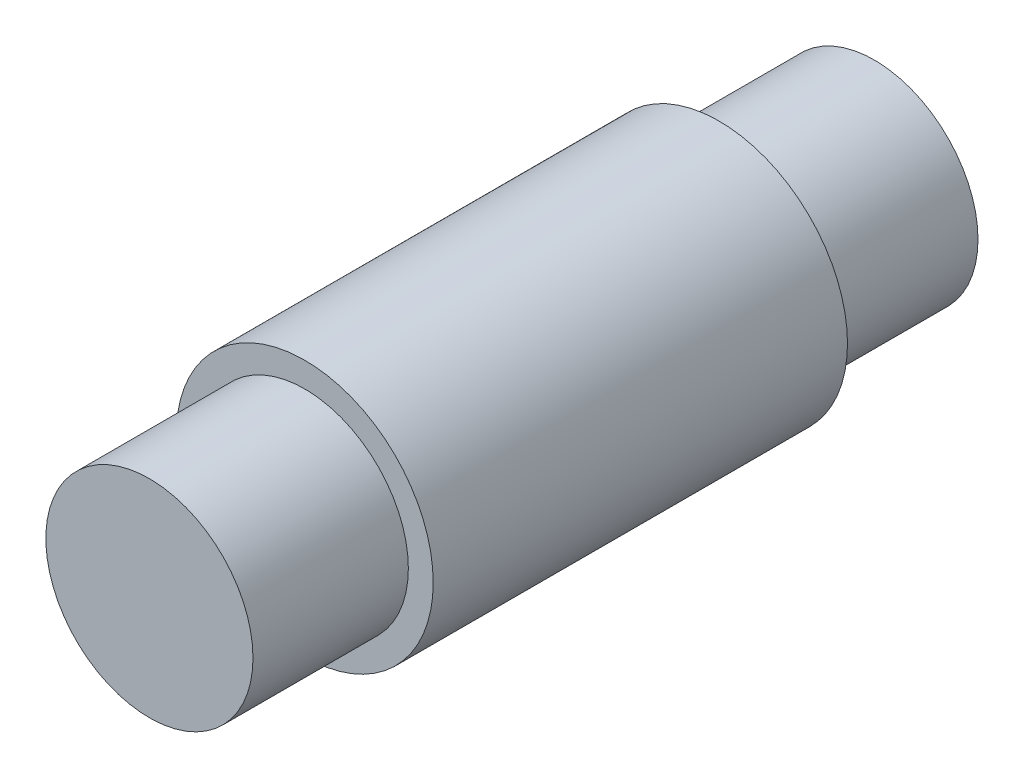
from build123d import *

# Parameters (mm, degrees)
SKETCH3_R           = 1.55
BOSS_EXTRUDE1_DEPTH = 2.5
SKETCH4_R           = 1.25
BOSS_EXTRUDE2_DEPTH = 1.875


with BuildPart() as part:
    # Sketch3 → Boss-Extrude1 (new body, symmetric)
    with BuildSketch(Plane.XY):
        Circle(SKETCH3_R)
    extrude(amount=BOSS_EXTRUDE1_DEPTH, both=True)

    # Sketch4 → Boss-Extrude2 (add)
    with BuildSketch(Plane.XY.offset(2.5)):
        Circle(SKETCH4_R)
    boss_extrude2 = extrude(amount=BOSS_EXTRUDE2_DEPTH)

    # Mirror1: Boss-Extrude2 across plane
    add(boss_extrude2.mirror(Plane.XY))


solid = part.part
